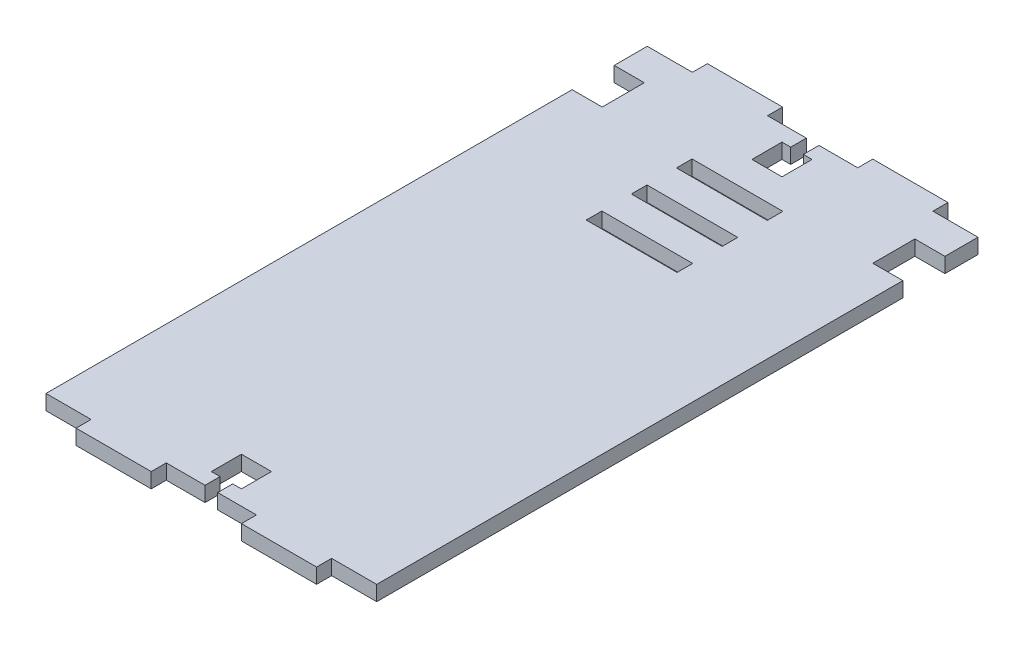
from build123d import *

# Parameters (mm, degrees)
SKETCH1_W           = 110
SKETCH1_H           = 5
BOSS_EXTRUDE1_DEPTH = 200
SKETCH2_W           = 25
SKETCH2_H           = 5
BOSS_EXTRUDE2_DEPTH = 5
SKETCH4_W           = 30.2
SKETCH4_H           = 5.2
CUT_EXTRUDE1_DEPTH  = 5
SKETCH5_W           = 4.2
SKETCH5_H           = 5.2
SKETCH5_W_2         = 10
SKETCH5_H_2         = 10
SKETCH5_H_3         = 5
CUT_EXTRUDE2_DEPTH  = 10
SKETCH6_W           = 10
SKETCH6_H           = 5
CUT_EXTRUDE3_DEPTH  = 5
SKETCH7_W           = 10
SKETCH7_H           = 9
CUT_EXTRUDE4_DEPTH  = 10


with BuildPart() as part:
    # Sketch1 → Boss-Extrude1 (new body)
    with BuildSketch(Plane.XY):
        with Locations((-55, 2.5)):
            Rectangle(SKETCH1_W, SKETCH1_H)
    extrude(amount=BOSS_EXTRUDE1_DEPTH)

    # Sketch2 → Boss-Extrude2 (add)
    with BuildSketch(Plane(origin=(0, 5, 0), x_dir=(1, 0, 0), z_dir=(0, 1, 0))):
        with Locations((-82.5, 2.5)):
            Rectangle(SKETCH2_W, SKETCH2_H)
        with Locations((-27.5, 2.5)):
            Rectangle(SKETCH2_W, SKETCH2_H)
        with Locations((-27.5, -202.5)):
            Rectangle(SKETCH2_W, SKETCH2_H)
        with Locations((-82.5, -202.5)):
            Rectangle(SKETCH2_W, SKETCH2_H)
    extrude(amount=-BOSS_EXTRUDE2_DEPTH)

    # Sketch4 → Cut-Extrude1 (cut)
    with BuildSketch(Plane(origin=(0, 5, 0), x_dir=(1, 0, 0), z_dir=(0, 1, 0))):
        with Locations((-55, -27.6)):
            Rectangle(SKETCH4_W, SKETCH4_H)
        with Locations((-55, -42.6)):
            Rectangle(SKETCH4_W, SKETCH4_H)
        with Locations((-55, -57.6)):
            Rectangle(SKETCH4_W, SKETCH4_H)
    extrude(amount=-CUT_EXTRUDE1_DEPTH, mode=Mode.SUBTRACT)

    # Sketch5 → Cut-Extrude2 (cut)
    with BuildSketch(Plane(origin=(0, 5, 0), x_dir=(1, 0, 0), z_dir=(0, 1, 0))):
        with Locations((-55, -2.6)):
            Rectangle(SKETCH5_W, SKETCH5_H)
        with Locations((-55, -10.2)):
            Rectangle(SKETCH5_W_2, SKETCH5_H_2)
        with Locations((-55, -197.5)):
            Rectangle(SKETCH5_W, SKETCH5_H_3)
        with Locations((-55, -190)):
            Rectangle(SKETCH5_W_2, SKETCH5_H_2)
    extrude(amount=-CUT_EXTRUDE2_DEPTH, mode=Mode.SUBTRACT)

    # Sketch6 → Cut-Extrude3 (cut)
    with BuildSketch(Plane(origin=(0, 5, 0), x_dir=(1, 0, 0), z_dir=(0, 1, 0))):
        with Locations((-105, -22.5)):
            Rectangle(SKETCH6_W, SKETCH6_H)
        with Locations((-5, -22.5)):
            Rectangle(SKETCH6_W, SKETCH6_H)
    extrude(amount=-CUT_EXTRUDE3_DEPTH, mode=Mode.SUBTRACT)

    # Sketch7 → Cut-Extrude4 (cut)
    with BuildSketch(Plane.XZ):
        with Locations((-5, 15.5)):
            Rectangle(SKETCH7_W, SKETCH7_H)
        with Locations((-105, 15.5)):
            Rectangle(SKETCH7_W, SKETCH7_H)
    extrude(amount=-CUT_EXTRUDE4_DEPTH, mode=Mode.SUBTRACT)


solid = part.part
